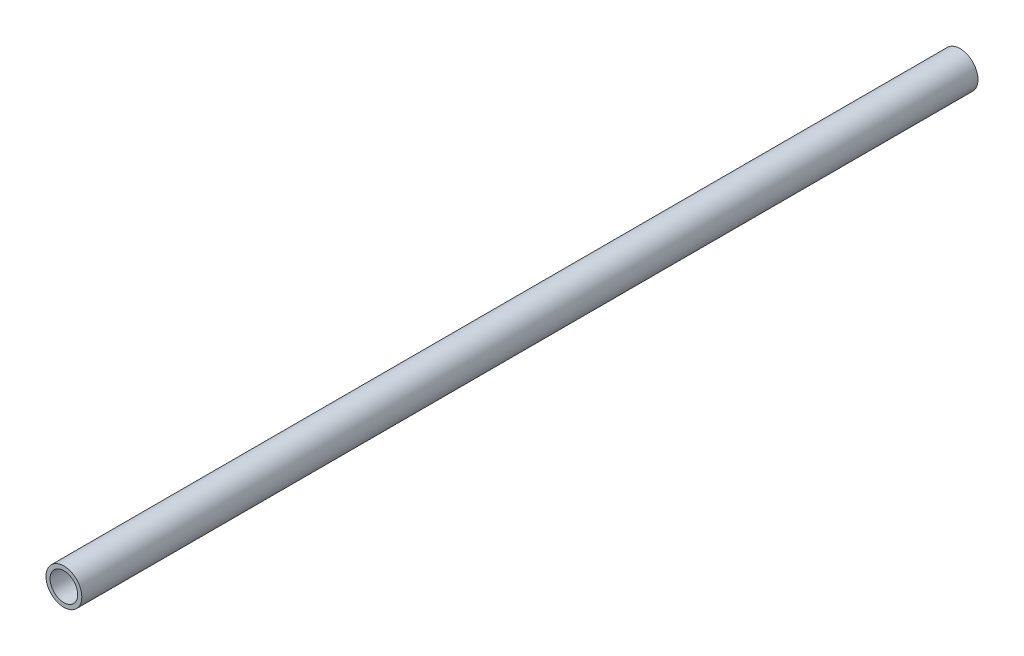
from build123d import *

# Parameters (mm, degrees)
SKETCH1_R           = 3.5
SKETCH1_R_2         = 2.7
BOSS_EXTRUDE1_DEPTH = 175


with BuildPart() as part:
    # Sketch1 → Boss-Extrude1 (new body)
    with BuildSketch(Plane.XY):
        with Locations((-655.992889877, -1.919458309)):
            Circle(SKETCH1_R)
        with Locations((-655.992889877, -1.919458309)):
            Circle(SKETCH1_R_2, mode=Mode.SUBTRACT)
    extrude(amount=BOSS_EXTRUDE1_DEPTH)


solid = part.part
